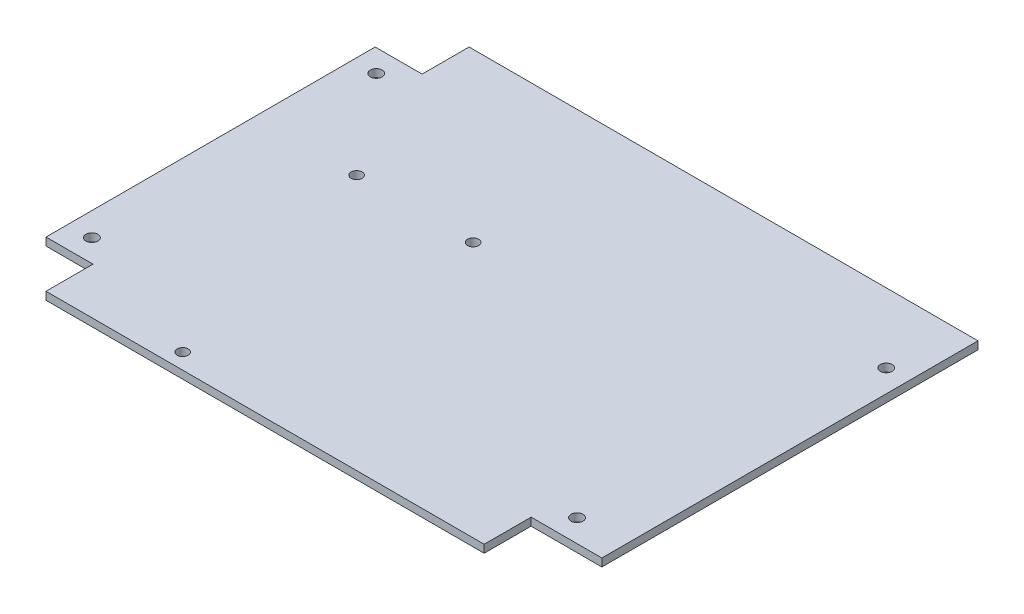
from build123d import *

# Parameters (mm, degrees)
SKETCH1_W             = 225.5266
SKETCH1_H             = 171.6532
BOSS_EXTRUDE1_DEPTH   = 3.175
SKETCH2_W             = 19.05
SKETCH2_H             = 19.05
SKETCH2_W_2           = 28.702
CORNERCUT_DEPTH       = 4.175
SKETCH3_R             = 2.4257
MOUNTHOLES_DEPTH      = 4.175
F_8_CLEARANCE_HOLE1_D = 4.4958


with BuildPart() as part:
    # Sketch1 → Boss-Extrude1 (new body)
    with BuildSketch(Plane(origin=(0, 0, 0), x_dir=(1, 0, 0), z_dir=(0, 1, 0))):
        Rectangle(SKETCH1_W, SKETCH1_H)
    extrude(amount=BOSS_EXTRUDE1_DEPTH)

    # Sketch2 → CornerCut (cut, through all)
    with BuildSketch(Plane(origin=(0, 3.175, 0), x_dir=(1, 0, 0), z_dir=(0, 1, 0))):
        with Locations((-103.2383, 76.3016)):
            Rectangle(SKETCH2_W, SKETCH2_H)
        with Locations((98.4123, -76.3016)):
            Rectangle(SKETCH2_W_2, SKETCH2_H)
        with Locations((-103.2383, -76.3016)):
            Rectangle(SKETCH2_W, SKETCH2_H)
    extrude(amount=-CORNERCUT_DEPTH, mode=Mode.SUBTRACT)

    # Sketch3 → MountHoles (cut, through all)
    with BuildSketch(Plane(origin=(0, 3.175, 0), x_dir=(1, 0, 0), z_dir=(0, 1, 0))):
        with Locations((-103.2383, 57.6834)):
            Circle(SKETCH3_R)
        with Locations((-103.2383, -57.6834)):
            Circle(SKETCH3_R)
        with Locations((93.5863, -57.6834)):
            Circle(SKETCH3_R)
        with Locations((103.6701, 57.6834)):
            Circle(SKETCH3_R)
    extrude(amount=-MOUNTHOLES_DEPTH, mode=Mode.SUBTRACT)

    # #8 Clearance Hole1 (through all)
    with Locations(Plane(origin=(0, 3.175, 0), x_dir=(1, 0, 0), z_dir=(0, 1, 0))):
        with Locations((-44.629848387, -79.4766), (-24.2443, 17.982191502), (-71.4883, 17.982191502)):
            Hole(F_8_CLEARANCE_HOLE1_D / 2)


solid = part.part
